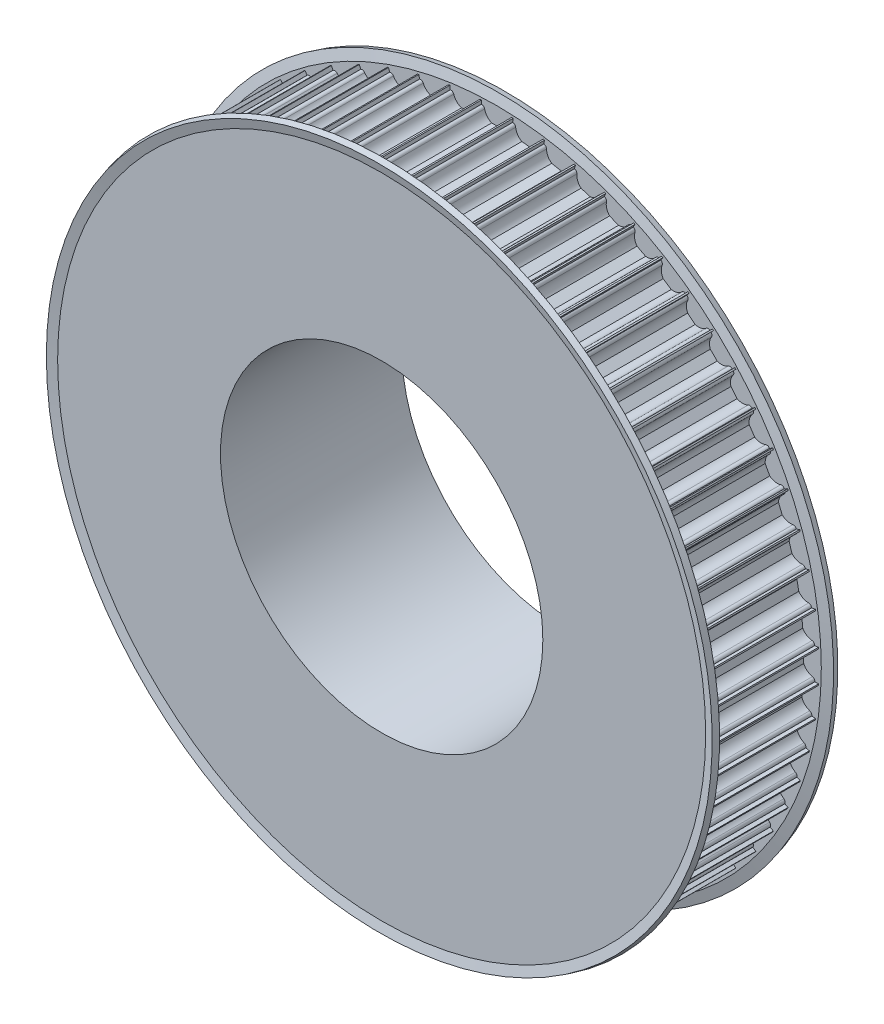
from build123d import *

# Parameters (mm, degrees)
CUT_EXTRUDE1_DEPTH = 30
CIRPATTERN2_COUNT  = 64


with BuildPart() as part:
    # Sketch1 → Revolve1 (revolve)
    with BuildSketch(Plane(origin=(0, 0, 0), x_dir=(0, 0, -1), z_dir=(1, 0, 0))):
        Polygon((0, 40), (0, 80), (30, 80), (30, 55.5), (45, 55.5), (45, 40), align=None)
    revolve(axis=Axis((0, 0, 0), (0, 0, -1)))

    # Sketch2 → Cut-Extrude1 (cut)
    with BuildSketch(Plane.XY):
        with BuildLine():
            Line((-3.674234614, 79), (-3.75, 79))
            Line((-3.75, 79), (-3.75, 81))
            Line((-3.75, 81), (3.75, 81))
            Line((3.75, 81), (3.75, 79))
            Line((3.75, 79), (3.674234614, 79))
            ThreePointArc((3.674234614, 79), (3.199892965, 78.830947502), (2.939387691, 78.4))
            ThreePointArc((2.939387691, 78.4), (2.331759211, 77.112435701), (1.198957881, 76.25))
            Line((1.198957881, 76.25), (-1.198957881, 76.25))
            ThreePointArc((-1.198957881, 76.25), (-2.331759211, 77.112435701), (-2.939387691, 78.4))
            ThreePointArc((-2.939387691, 78.4), (-3.199892965, 78.830947502), (-3.674234614, 79))
        make_face()
    cut_extrude1 = extrude(amount=-CUT_EXTRUDE1_DEPTH, mode=Mode.SUBTRACT)

    # CirPattern2: Cut-Extrude1 ×64 about axis
    cirpattern2_axis = Axis((0, 0, 0), (0, 0, 1))
    for i in range(1, CIRPATTERN2_COUNT):
        add(cut_extrude1.rotate(cirpattern2_axis, i * 360 / CIRPATTERN2_COUNT), mode=Mode.SUBTRACT)

    # Sketch3 → Revolve2 (revolve)
    with BuildSketch(Plane(origin=(0, 0, 0), x_dir=(0, 0, -1), z_dir=(1, 0, 0))):
        Polygon((30, 55.5), (30, 80.412521254), (30.591966801, 82.621771432), (29.143078062, 83.01), (28.5, 80.61), (28.5, 55.5), align=None)
        Polygon((0, 80.412521254), (-0.591966801, 82.621771432), (0.856921938, 83.01), (1.5, 80.61), (1.5, 55.5), (0, 55.5), align=None)
    revolve(axis=Axis((0, 0, 0), (0, 0, 1)))


solid = part.part
